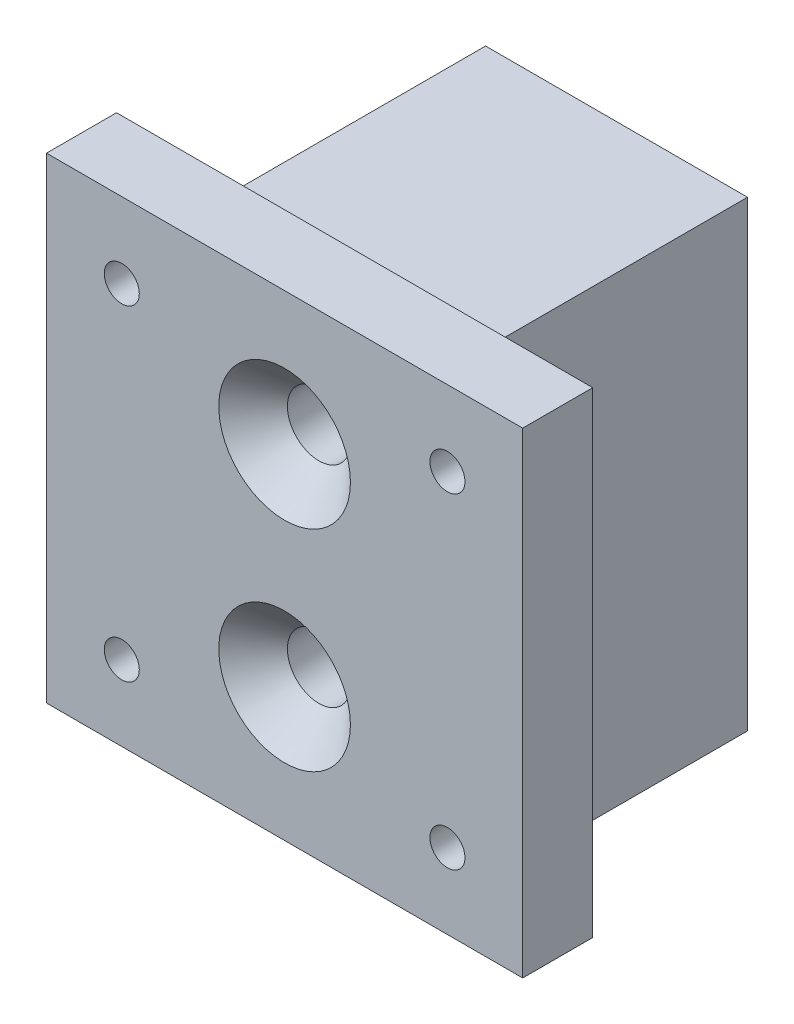
from build123d import *

# Parameters (mm, degrees)
SKETCH3_W                                       = 18.7
SKETCH3_H                                       = 18.7
SKETCH3_W_2                                     = 12.7
SKETCH3_H_2                                     = 12.7
BOSS_EXTRUDE2_DEPTH                             = 30
SKETCH4_W                                       = 18.7
SKETCH4_H                                       = 18.7
BOSS_EXTRUDE3_DEPTH                             = 3
SKETCH9_W                                       = 34
SKETCH9_H                                       = 34
BOSS_EXTRUDE4_DEPTH                             = 5
CSK_FOR_M4_FLAT_HEAD_MACHINE_SCREW3_D           = 4.5
CSK_FOR_M4_FLAT_HEAD_MACHINE_SCREW3_CSINK_D     = 9.4
CSK_FOR_M4_FLAT_HEAD_MACHINE_SCREW3_CSINK_ANGLE = 90
TAP_DRILL_FOR_M3X0_5_TAP1_D                     = 2.5


with BuildPart() as part:
    # Sketch3 → Boss-Extrude2 (new body)
    with BuildSketch(Plane(origin=(0, 0, 0), x_dir=(1, 0, 0), z_dir=(0, 1, 0))):
        with Locations((9.35, 9.35)):
            Rectangle(SKETCH3_W, SKETCH3_H)
        with Locations((9.35, 9.35)):
            Rectangle(SKETCH3_W_2, SKETCH3_H_2, mode=Mode.SUBTRACT)
    extrude(amount=BOSS_EXTRUDE2_DEPTH)

    # Sketch4 → Boss-Extrude3 (add)
    with BuildSketch(Plane(origin=(0, 30, 0), x_dir=(1, 0, 0), z_dir=(0, 1, 0))):
        with Locations((9.35, 9.35)):
            Rectangle(SKETCH4_W, SKETCH4_H)
    extrude(amount=BOSS_EXTRUDE3_DEPTH)

    # Sketch9 → Boss-Extrude4 (add)
    with BuildSketch(Plane.XY):
        with Locations((9.35, 17.4)):
            Rectangle(SKETCH9_W, SKETCH9_H)
    extrude(amount=BOSS_EXTRUDE4_DEPTH)

    # CSK for M4 Flat Head Machine Screw3 (through all)
    with Locations(Plane(origin=(9.35, 24.9, 5), x_dir=(1, 0, 0), z_dir=(0, 0, 1))):
        with Locations((0, 0), (0, -15)):
            CounterSinkHole(CSK_FOR_M4_FLAT_HEAD_MACHINE_SCREW3_D / 2, CSK_FOR_M4_FLAT_HEAD_MACHINE_SCREW3_CSINK_D / 2, counter_sink_angle=CSK_FOR_M4_FLAT_HEAD_MACHINE_SCREW3_CSINK_ANGLE)

    # Tap Drill for M3x0.5 Tap1 (through all)
    with Locations(Plane(origin=(-2.275, 29.025, 5), x_dir=(1, 0, 0), z_dir=(0, 0, 1))):
        with Locations((0, 0), (23.25, 0), (0, -23.25), (23.25, -23.25)):
            Hole(TAP_DRILL_FOR_M3X0_5_TAP1_D / 2)


solid = part.part
